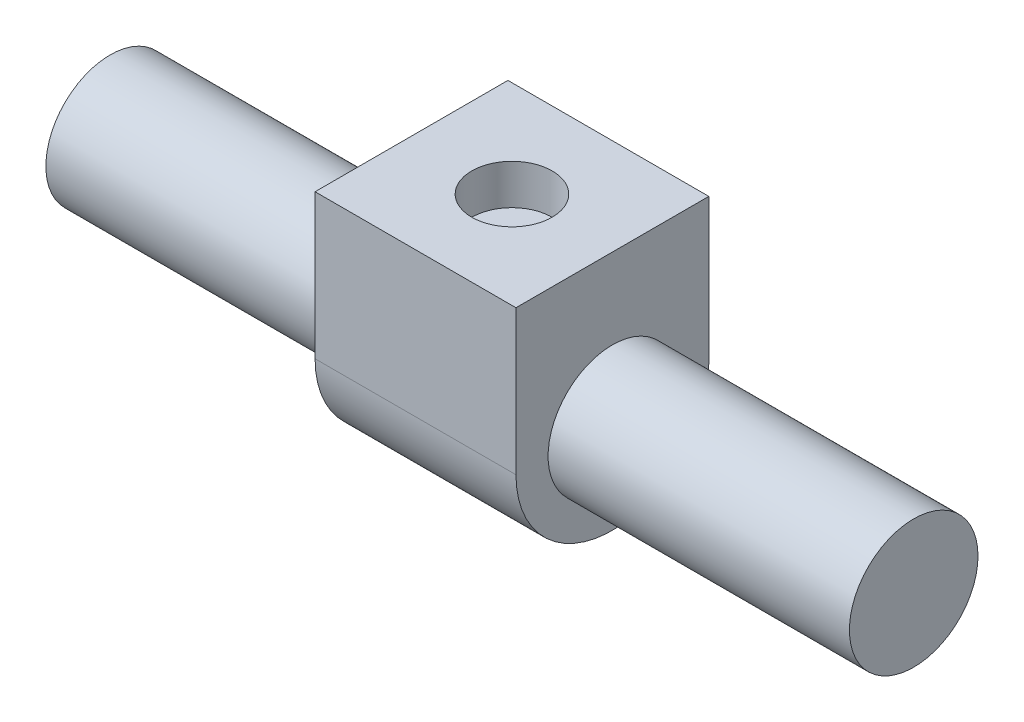
from build123d import *

# Parameters (mm, degrees)
BOSS_EXTRUDE1_DEPTH = 12.5
SKETCH2_R           = 8
BOSS_EXTRUDE2_DEPTH = 50
SKETCH3_R           = 5
CUT_EXTRUDE1_DEPTH  = 5


with BuildPart() as part:
    # Sketch1 → Boss-Extrude1 (new body, symmetric)
    with BuildSketch(Plane(origin=(0, 0, 0), x_dir=(0, 0, -1), z_dir=(1, 0, 0))):
        with BuildLine():
            Line((-12, 0), (-12, 18))
            Line((-12, 18), (12, 18))
            Line((12, 18), (12, 0))
            ThreePointArc((12, 0), (0, -12), (-12, 0))
        make_face()
    extrude(amount=BOSS_EXTRUDE1_DEPTH, both=True)

    # Sketch2 → Boss-Extrude2 (add, symmetric)
    with BuildSketch(Plane(origin=(0, 0, 0), x_dir=(0, 0, -1), z_dir=(1, 0, 0))):
        Circle(SKETCH2_R)
    extrude(amount=BOSS_EXTRUDE2_DEPTH, both=True)

    # Sketch3 → Cut-Extrude1 (cut)
    with BuildSketch(Plane(origin=(0, 18, 0), x_dir=(1, 0, 0), z_dir=(0, 1, 0))):
        Circle(SKETCH3_R)
    extrude(amount=-CUT_EXTRUDE1_DEPTH, mode=Mode.SUBTRACT)


solid = part.part
